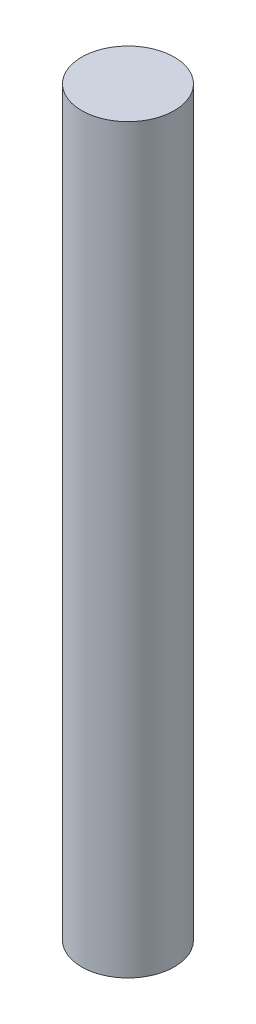
from build123d import *

# Parameters (mm, degrees)
SKETCH1_R           = 2.5
BOSS_EXTRUDE1_DEPTH = 20


with BuildPart() as part:
    # Sketch1 → Boss-Extrude1 (new body, symmetric)
    with BuildSketch(Plane(origin=(0, 0, 0), x_dir=(1, 0, 0), z_dir=(0, 1, 0))):
        Circle(SKETCH1_R)
    extrude(amount=BOSS_EXTRUDE1_DEPTH, both=True)


solid = part.part
